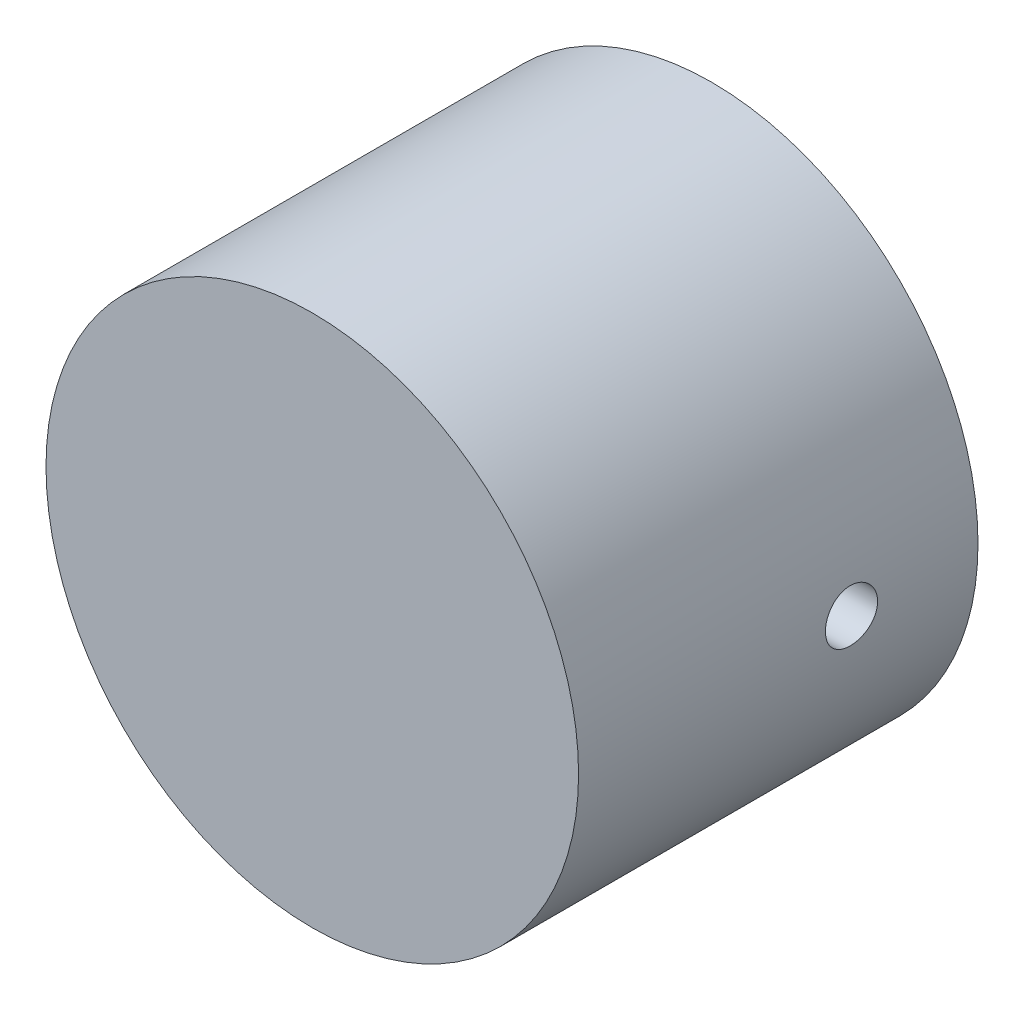
from build123d import *

# Parameters (mm, degrees)
SKETCH1_R               = 12.7
BOSS_EXTRUDE1_DEPTH     = 19.05
SHELL1_T                = -3.175
SKETCH4_R               = 1.2446
CUT_EXTRUDE1_DEPTH      = 27.181720723
CUT_EXTRUDE1_DEPTH_BACK = 27.181720723
SKETCH7_R               = 10.8712
SKETCH7_R_2             = 9.525
CUT_EXTRUDE2_DEPTH      = 2.3622


with BuildPart() as part:
    # Sketch1 → Boss-Extrude1 (new body)
    with BuildSketch(Plane.XY):
        Circle(SKETCH1_R)
    extrude(amount=-BOSS_EXTRUDE1_DEPTH)

    # Shell1
    shell1_openings = [part.faces().sort_by_distance(p)[0] for p in [
        (0, 0, -19.05),
    ]]
    offset(amount=SHELL1_T, openings=shell1_openings, kind=Kind.INTERSECTION)

    # Sketch4 → Cut-Extrude1 (cut, two sides)
    with BuildSketch(Plane(origin=(0, 0, 0), x_dir=(0, 0, -1), z_dir=(1, 0, 0))) as cut_extrude1_sk:
        with Locations((13.0175, 0)):
            Circle(SKETCH4_R)
    extrude(amount=CUT_EXTRUDE1_DEPTH, mode=Mode.SUBTRACT)
    extrude(cut_extrude1_sk.sketch, amount=-CUT_EXTRUDE1_DEPTH_BACK, mode=Mode.SUBTRACT)

    # Sketch7 → Cut-Extrude2 (cut)
    with BuildSketch(Plane(origin=(0, 0, -17.78), x_dir=(-1, 0, 0), z_dir=(0, 0, -1))):
        Circle(SKETCH7_R)
        with Locations(Location((0, 0, 0), (0, 0, 180))):
            Circle(SKETCH7_R_2, mode=Mode.SUBTRACT)
    extrude(amount=-CUT_EXTRUDE2_DEPTH, mode=Mode.SUBTRACT)


solid = part.part
